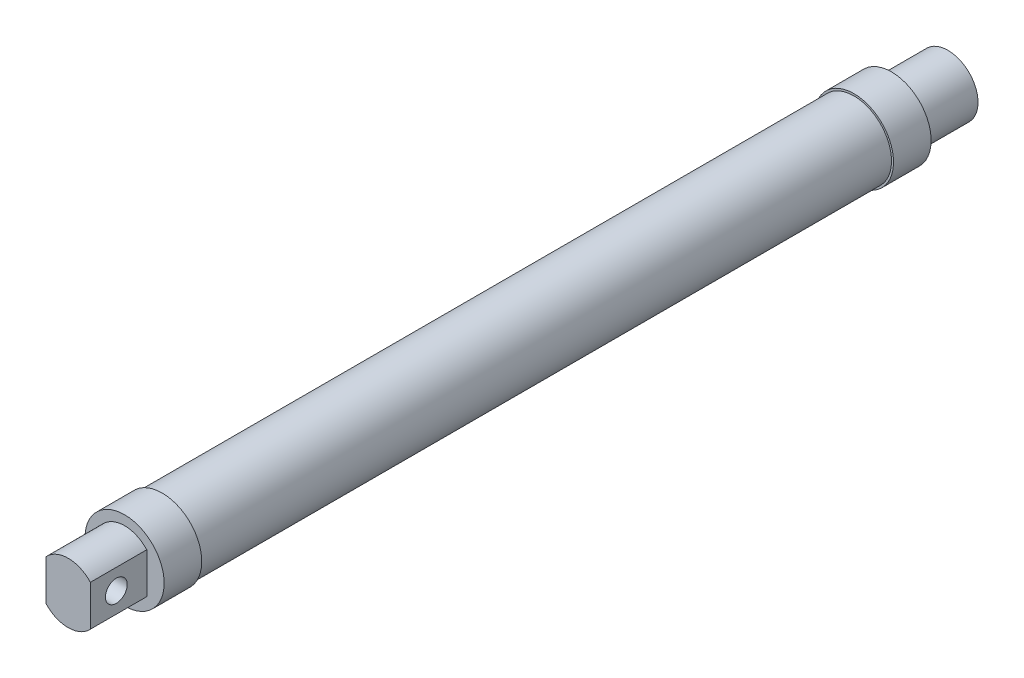
from build123d import *

# Parameters (mm, degrees)
CUT_EXTRUDE1_DEPTH = 15
SKETCH4_R          = 2.9
CUT_EXTRUDE2_DEPTH = 17.425
SKETCH5_R          = 3
CUT_EXTRUDE3_DEPTH = 180


with BuildPart() as part:
    # Sketch2 → Revolve1 (revolve)
    with BuildSketch(Plane(origin=(0, 0, 0), x_dir=(0, 0, -1), z_dir=(1, 0, 0))):
        Polygon((116.173333333, 10.525), (116.173333333, 8), (131.173333333, 8), (131.173333333, 0), (-102.826666667, 0), (-102.826666667, 8), (-87.826666667, 8), (-87.826666667, 10.525), (-77.826666667, 10.525), (-77.826666667, 10), (106.173333333, 10), (106.173333333, 10.525), align=None)
    revolve(axis=Axis((0, 0, -131.173333333), (0, 0, 1)))

    # Sketch3 → Cut-Extrude1 (cut)
    with BuildSketch(Plane.XY.offset(102.826666667)):
        with BuildLine():
            Line((-5.9, 5.402777064), (-5.9, -5.402777064))
            ThreePointArc((-5.9, -5.402777064), (-8, 0), (-5.9, 5.402777064))
        make_face()
        with BuildLine():
            Line((5.9, -5.402777064), (5.9, 5.402777064))
            ThreePointArc((5.9, 5.402777064), (8, 0), (5.9, -5.402777064))
        make_face()
    extrude(amount=-CUT_EXTRUDE1_DEPTH, mode=Mode.SUBTRACT)

    # Sketch4 → Cut-Extrude2 (cut, through all)
    with BuildSketch(Plane(origin=(5.9, 0, 0), x_dir=(0, 0, -1), z_dir=(1, 0, 0))):
        with Locations(Location((-95.926666667, 0, 0), (0, 0, 90))):  # turned: the seam where the file's is
            Circle(SKETCH4_R)
    extrude(amount=-CUT_EXTRUDE2_DEPTH, mode=Mode.SUBTRACT)

    # Sketch5 → Cut-Extrude3 (cut)
    with BuildSketch(Plane(origin=(0, 0, -131.173333333), x_dir=(-1, 0, 0), z_dir=(0, 0, -1))):
        with Locations(Location((0, 0, 0), (0, 0, 90))):  # turned: the seam where the file's is
            Circle(SKETCH5_R)
    extrude(amount=-CUT_EXTRUDE3_DEPTH, mode=Mode.SUBTRACT)


solid = part.part
